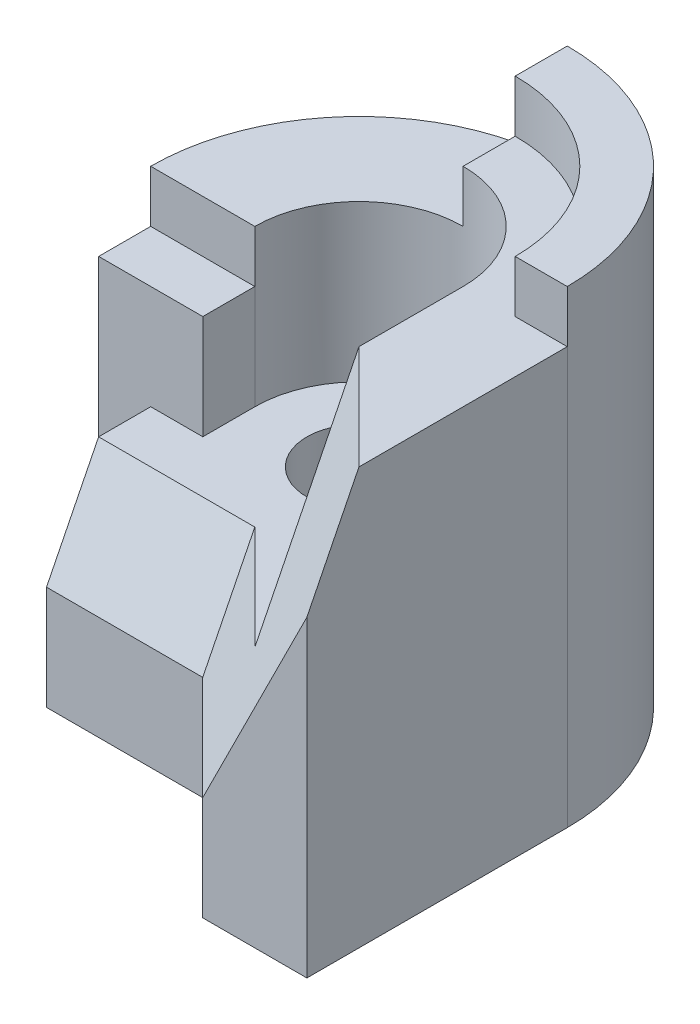
from build123d import *

# Parameters (mm, degrees)
BOSS_EXTRUDE1_DEPTH = 90
SKETCH2_R           = 10
CUT_EXTRUDE1_DEPTH  = 90
CUT_EXTRUDE2_DEPTH  = 10
CUT_EXTRUDE3_DEPTH  = 20
SKETCH11_W          = 10
SKETCH11_H          = 9.986072288
BOSS_EXTRUDE2_DEPTH = 70
SKETCH12_W          = 20
SKETCH12_H          = 9.986072288
CUT_EXTRUDE11_DEPTH = 10
CUT_EXTRUDE25_DEPTH = 30
CUT_EXTRUDE26_DEPTH = 30
CUT_EXTRUDE27_DEPTH = 83


with BuildPart() as part:
    # Sketch1 → Boss-Extrude1 (new body)
    with BuildSketch(Plane(origin=(0, 0, 0), x_dir=(1, 0, 0), z_dir=(0, 1, 0))):
        with BuildLine():
            Line((-40, 0), (-30, 0))
            Line((-30, 0), (-30, -30))
            Line((-30, -30), (0, -30))
            Line((0, -30), (20, -50))
            Line((20, -50), (40, -50))
            Line((40, -50), (40, 0))
            ThreePointArc((40, 0), (0, 40), (-40, 0))
        make_face()
    extrude(amount=BOSS_EXTRUDE1_DEPTH)

    # Sketch2 → Cut-Extrude1 (cut)
    with BuildSketch(Plane(origin=(0, 90, 0), x_dir=(1, 0, 0), z_dir=(0, 1, 0))):
        with Locations(Location((0, 0, 0), (0, 0, 270))):
            Circle(SKETCH2_R)
    extrude(amount=-CUT_EXTRUDE1_DEPTH, mode=Mode.SUBTRACT)

    # Sketch3 → Cut-Extrude2 (cut)
    with BuildSketch(Plane(origin=(0, 90, 0), x_dir=(1, 0, 0), z_dir=(0, 1, 0))):
        with BuildLine():
            Line((30, 0), (40, 0))
            Line((40, 0), (40, -40))
            Line((40, -40), (20, -20))
            Line((20, -20), (20, 0))
            ThreePointArc((20, 0), (14.142135624, 14.142135624), (0, 20))
            Line((0, 20), (0, 30))
            ThreePointArc((0, 30), (21.213203436, 21.213203436), (30, 0))
        make_face()
    extrude(amount=-CUT_EXTRUDE2_DEPTH, mode=Mode.SUBTRACT)

    # Sketch4 → Cut-Extrude3 (cut)
    with BuildSketch(Plane(origin=(0, 90, 0), x_dir=(1, 0, 0), z_dir=(0, 1, 0))):
        with BuildLine():
            Line((0, 40), (0, 20))
            ThreePointArc((0, 20), (14.142135624, 14.142135624), (20, 0))
            Line((20, 0), (20, -20))
            Line((20, -20), (20, -59.206848118))
            Line((20, -59.206848118), (-30, -59.206848118))
            Line((-30, -59.206848118), (-30, 0))
            Line((-30, 0), (-40, 0))
            ThreePointArc((-40, 0), (-28.284271247, 28.284271247), (0, 40))
        make_face()
    extrude(amount=-CUT_EXTRUDE3_DEPTH, mode=Mode.SUBTRACT)

    # Sketch11 → Boss-Extrude2 (add)
    with BuildSketch(Plane(origin=(0, 70, 0), x_dir=(1, 0, 0), z_dir=(0, 1, 0))):
        with Locations((-35, -4.993036144)):
            Rectangle(SKETCH11_W, SKETCH11_H)
    extrude(amount=-BOSS_EXTRUDE2_DEPTH)

    # Sketch12 → Cut-Extrude11 (cut)
    with BuildSketch(Plane(origin=(0, 70, 0), x_dir=(1, 0, 0), z_dir=(0, 1, 0))):
        with Locations((-30, -4.993036144)):
            Rectangle(SKETCH12_W, SKETCH12_H)
    extrude(amount=-CUT_EXTRUDE11_DEPTH, mode=Mode.SUBTRACT)

    # Sketch21 → Cut-Extrude25 (cut)
    with BuildSketch(Plane(origin=(0, 70, 0), x_dir=(1, 0, 0), z_dir=(0, 1, 0))):
        with BuildLine():
            Line((-20, 0), (-20, -9.986072288))
            Line((-20, -9.986072288), (-30, -9.986072288))
            Line((-30, -9.986072288), (-30, -30))
            Line((-30, -30), (-20, -30))
            Line((-20, -30), (-20, -44.965046587))
            Line((-20, -44.965046587), (20, -44.965046587))
            Line((20, -44.965046587), (20, 0))
            ThreePointArc((20, 0), (0, 20), (-20, 0))
        make_face()
    extrude(amount=-CUT_EXTRUDE25_DEPTH, mode=Mode.SUBTRACT)

    # Sketch22 → Cut-Extrude26 (cut)
    with BuildSketch(Plane.ZY.offset(30)):
        Polygon((20, 40), (30, 20), (30, 40), align=None)
    extrude(amount=-CUT_EXTRUDE26_DEPTH, mode=Mode.SUBTRACT)

    # 3DSketch3 → Cut-Extrude27 (cut, along a direction that is not the sketch's normal)
    with BuildSketch(Plane(origin=(0, 20, 30), x_dir=(0.549442255794756, 0.8241633836921342, 0.1373605639486891), z_dir=(-0.6666666666666666, 0.3333333333333332, 0.6666666666666669))):
        Polygon((0, 0), (15.109662034, 16.483267674), (28.845718429, -8.241633837), (59.065042498, 24.724901511), (72.801098893, 0), (57.691436858, -16.483267674), (13.736056395, -24.724901511), align=None)
    extrude(amount=CUT_EXTRUDE27_DEPTH, dir=(0, 1, 0), mode=Mode.SUBTRACT)


solid = part.part
